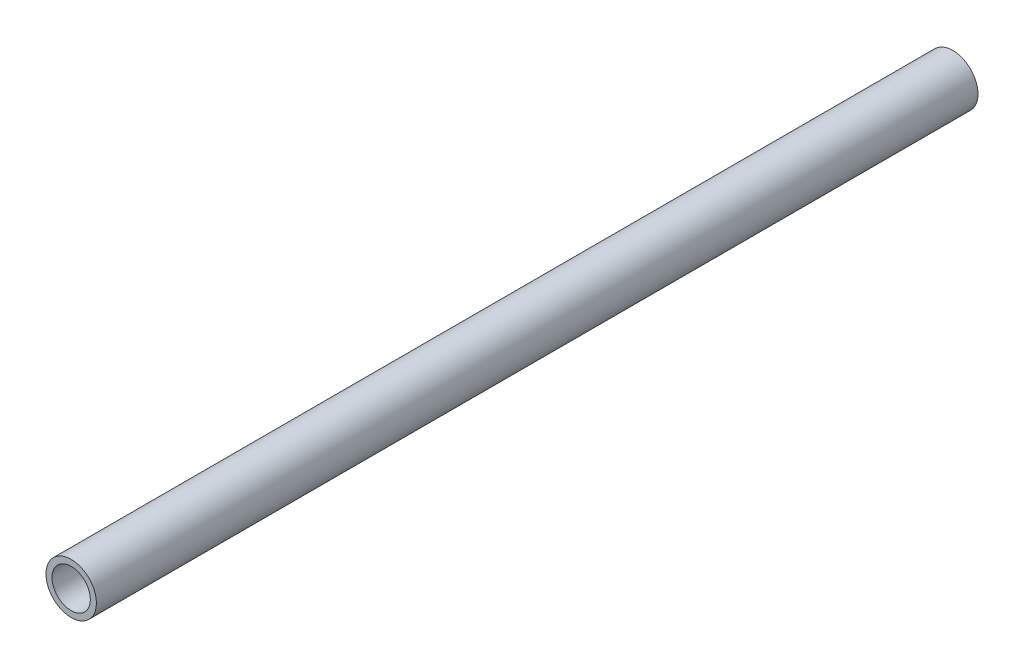
from build123d import *

# Parameters (mm, degrees)
SZKIC1_R                         = 8.35
SZKIC1_R_2                       = 6.35
DODANIE_WYCI_GNI_CIE1_DEPTH      = 266.716847891
DODANIE_WYCI_GNI_CIE1_DEPTH_BACK = 25.233938


with BuildPart() as part:
    # Szkic1 → Dodanie-wyciągnięcie1 (new body, two sides)
    with BuildSketch(Plane.XY) as dodanie_wyci_gni_cie1_sk:
        Circle(SZKIC1_R)
        Circle(SZKIC1_R_2, mode=Mode.SUBTRACT)
    extrude(amount=DODANIE_WYCI_GNI_CIE1_DEPTH)
    extrude(dodanie_wyci_gni_cie1_sk.sketch, amount=-DODANIE_WYCI_GNI_CIE1_DEPTH_BACK)


solid = part.part
